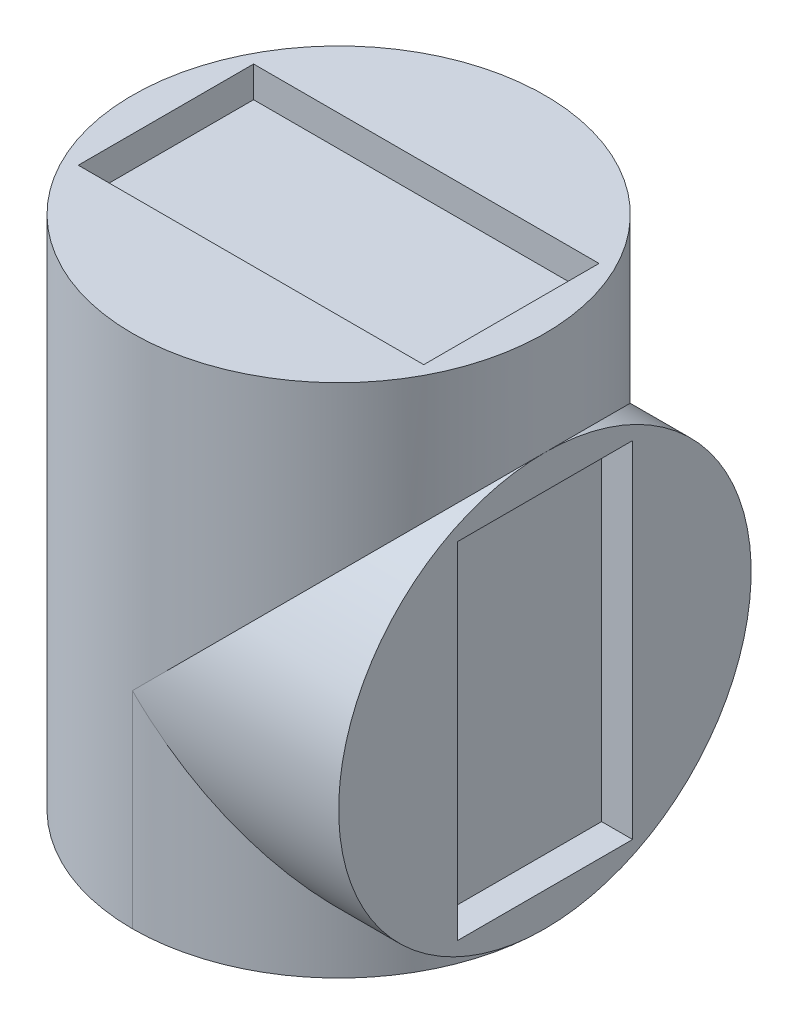
from build123d import *

# Parameters (mm, degrees)
CROQUIS1_R              = 20
SALIENTE_EXTRUIR1_DEPTH = 50
CROQUIS3_R              = 20
SALIENTE_EXTRUIR2_DEPTH = 20
CROQUIS4_W              = 33.5
CROQUIS4_H              = 17
CORTAR_EXTRUIR2_DEPTH   = 3
CROQUIS5_W              = 17
CROQUIS5_H              = 33.5
CORTAR_EXTRUIR3_DEPTH   = 3


with BuildPart() as part:
    # Croquis1 → Saliente-Extruir1 (new body)
    with BuildSketch(Plane(origin=(0, 0, 0), x_dir=(1, 0, 0), z_dir=(0, 1, 0))):
        Circle(CROQUIS1_R)
    extrude(amount=SALIENTE_EXTRUIR1_DEPTH)

    # Croquis3 → Saliente-Extruir2 (add)
    with BuildSketch(Plane(origin=(0, 0, 0), x_dir=(0, 0, -1), z_dir=(1, 0, 0))):
        with Locations((0, 20)):
            Circle(CROQUIS3_R)
    extrude(amount=SALIENTE_EXTRUIR2_DEPTH)

    # Croquis4 → Cortar-Extruir2 (cut)
    with BuildSketch(Plane(origin=(0, 50, 0), x_dir=(1, 0, 0), z_dir=(0, 1, 0))):
        Rectangle(CROQUIS4_W, CROQUIS4_H)
    extrude(amount=-CORTAR_EXTRUIR2_DEPTH, mode=Mode.SUBTRACT)

    # Croquis5 → Cortar-Extruir3 (cut)
    with BuildSketch(Plane(origin=(20, 0, 0), x_dir=(0, 0, -1), z_dir=(1, 0, 0))):
        with Locations((0, 20)):
            Rectangle(CROQUIS5_W, CROQUIS5_H)
    extrude(amount=-CORTAR_EXTRUIR3_DEPTH, mode=Mode.SUBTRACT)


solid = part.part
